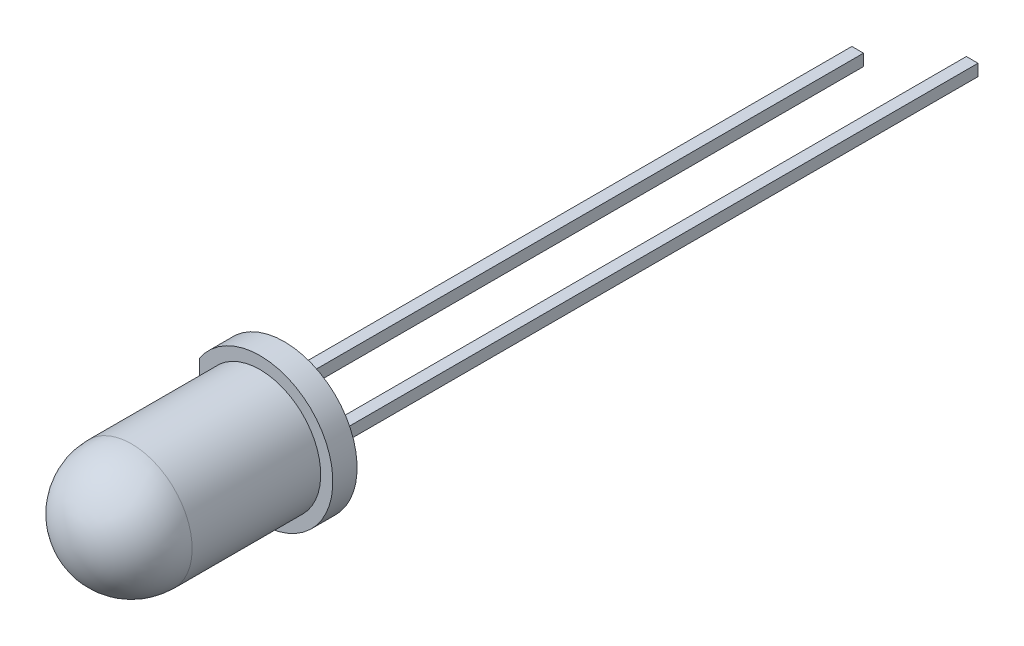
from build123d import *

# Parameters (mm, degrees)
ESBO_O1_R                  = 3
RESSALTO_EXTRUS_O1_DEPTH   = 1
CORTE_EXTRUS_O1_DEPTH      = 1
ESBO_O5_W                  = 0.48
ESBO_O5_H                  = 0.48
RESSALTO_EXTRUS_O2_DEPTH   = 25
RESSALTO_EXTRUS_O2_2_DEPTH = 25
ESBO_O6_W                  = 0.48
ESBO_O6_H                  = 0.48
RESSALTO_EXTRUS_O3_DEPTH   = 2
CORTE_EXTRUS_O2_DEPTH      = 0.24
RESSALTO_EXTRUS_O4_DEPTH   = 0.24
RESSALTO_EXTRUS_O4_2_DEPTH = 0.24
ESBO_O12_R                 = 0.2
CORTE_EXTRUS_O3_DEPTH      = 0.1


with BuildPart() as part:
    # Esbo_o1 → Ressalto-extrus_o1 (new body)
    with BuildSketch(Plane.XY):
        Circle(ESBO_O1_R)
    extrude(amount=RESSALTO_EXTRUS_O1_DEPTH)

    # Esbo_o3 → Revolu_o1 (revolve)
    with BuildSketch(Plane(origin=(0, 0, 0), x_dir=(0, 0, -1), z_dir=(1, 0, 0))):
        with BuildLine():
            Line((-1, 0), (-8.8, 0))
            ThreePointArc((-8.8, 0), (-8.067766953, 1.767766953), (-6.3, 2.5))
            Line((-6.3, 2.5), (-1, 2.5))
            Line((-1, 2.5), (-1, 0))
        make_face()
    revolve(axis=Axis((0, 0, 1), (0, 0, 1)))

    # Esbo_o4 → Corte-extrus_o1 (cut)
    with BuildSketch(Plane(origin=(0, 0, 0), x_dir=(-1, 0, 0), z_dir=(0, 0, -1))):
        with BuildLine():
            Line((2.5, 1.658312395), (2.5, -1.658312395))
            ThreePointArc((2.5, -1.658312395), (3, 0), (2.5, 1.658312395))
        make_face()
    extrude(amount=-CORTE_EXTRUS_O1_DEPTH, mode=Mode.SUBTRACT)

    # Esbo_o7 → Corte-extrus_o2 (cut, symmetric)
    with BuildSketch(Plane(origin=(0, 0, 0), x_dir=(1, 0, 0), z_dir=(0, 1, 0))):
        Polygon((-1.6, 0), (-1.6, -3.5), (-1.3, -4), (1.2, -4), (0.02, -2), (-1.12, -2), (-1.12, 0), align=None)
        Polygon((1.6, 0), (1.6, -4), (1.4, -4), (0.22, -2), (1.12, -2), (1.12, 0), align=None)
    extrude(amount=CORTE_EXTRUS_O2_DEPTH, both=True, mode=Mode.SUBTRACT)


with BuildPart() as body_2:
    # Esbo_o5 → Ressalto-extrus_o2 (new body)
    with BuildSketch(Plane(origin=(0, 0, 0), x_dir=(-1, 0, 0), z_dir=(0, 0, -1))):
        with Locations((-1.36, 0)):
            Rectangle(ESBO_O5_W, ESBO_O5_H)
    extrude(amount=RESSALTO_EXTRUS_O2_DEPTH)


with BuildPart() as body_3:
    # Esbo_o5 → Ressalto-extrus_o2 2 (new body)
    with BuildSketch(Plane(origin=(0, 0, 0), x_dir=(-1, 0, 0), z_dir=(0, 0, -1))):
        with Locations((1.36, 0)):
            Rectangle(ESBO_O5_W, ESBO_O5_H)
    extrude(amount=RESSALTO_EXTRUS_O2_2_DEPTH)


with BuildPart() as body_4:
    # Esbo_o6 → Ressalto-extrus_o3 (new body)
    with BuildSketch(Plane(origin=(0, 0, -25), x_dir=(-1, 0, 0), z_dir=(0, 0, -1))):
        with Locations((-1.36, 0)):
            Rectangle(ESBO_O6_W, ESBO_O6_H)
    extrude(amount=RESSALTO_EXTRUS_O3_DEPTH)


with BuildPart() as body_5:
    # Esbo_o8 → Ressalto-extrus_o4 (new body, symmetric)
    with BuildSketch(Plane(origin=(0, 0, 0), x_dir=(1, 0, 0), z_dir=(0, 1, 0))):
        Polygon((-1.3, -4), (1.2, -4), (0.02, -2), (-1.12, -2), (-1.12, 0), (-1.6, 0), (-1.6, -3.5), align=None)
    extrude(amount=RESSALTO_EXTRUS_O4_DEPTH, both=True)

    # Combinar2: union body 3
    add(body_3.part)

    # Esbo_o10 → Corte-Revolu_o1 (revolve, cut)
    with BuildSketch(Plane(origin=(0, 0, 0), x_dir=(1, 0, 0), z_dir=(0, 1, 0))):
        with BuildLine():
            Line((-0.05, -4), (-0.05, -3.7))
            ThreePointArc((-0.05, -3.7), (-0.341547595, -3.780754009), (-0.55, -4))
            Line((-0.55, -4), (-0.05, -4))
        make_face()
    revolve(axis=Axis((-0.05, 0, 4), (0, 0, -1)), mode=Mode.SUBTRACT)


with BuildPart() as body_6:
    # Esbo_o8 → Ressalto-extrus_o4 2 (new body, symmetric)
    with BuildSketch(Plane(origin=(0, 0, 0), x_dir=(1, 0, 0), z_dir=(0, 1, 0))):
        Polygon((0.22, -2), (1.4, -4), (1.6, -4), (1.6, 0), (1.12, 0), (1.12, -2), align=None)
    extrude(amount=RESSALTO_EXTRUS_O4_2_DEPTH, both=True)

    # Combinar1: union body 4, body 2
    add(body_4.part)
    add(body_2.part)


with BuildPart() as body_4_2:
    # Esbo_o11 → Revolu_o2 (revolve)
    with BuildSketch(Plane(origin=(0, 0, 0), x_dir=(1, 0, 0), z_dir=(0, 1, 0))):
        with BuildLine():
            Line((-0.55, -4), (-0.05, -4))
            Line((-0.05, -4), (-0.05, -3.7))
            ThreePointArc((-0.05, -3.7), (-0.341547595, -3.780754009), (-0.55, -4))
        make_face()
    revolve(axis=Axis((-0.05, 0, 4), (0, 0, -1)))

    # Combinar3: union body 5
    add(body_5.part)

    # Esbo_o12 → Corte-extrus_o3 (cut)
    with BuildSketch(Plane.XY.offset(4)):
        with Locations((-0.05, 0)):
            Circle(ESBO_O12_R)
    extrude(amount=-CORTE_EXTRUS_O3_DEPTH, mode=Mode.SUBTRACT)


solid = Compound([part.part, body_6.part, body_4_2.part])
